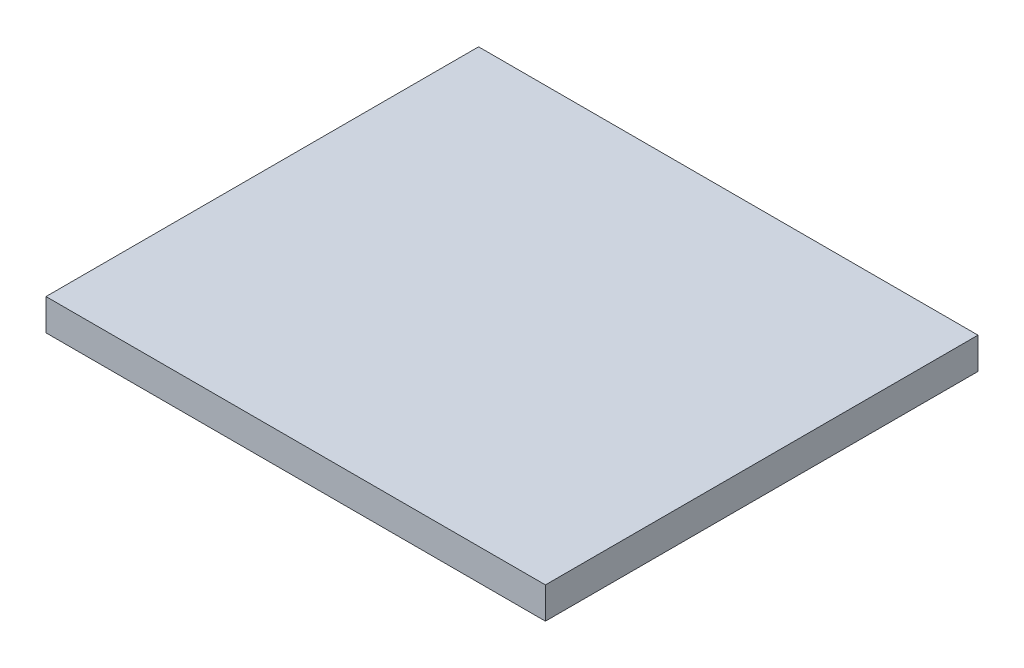
from build123d import *

# Parameters (mm, degrees)
CROQUIS1_W              = 101.6
CROQUIS1_H              = 6.4
SALIENTE_EXTRUIR2_DEPTH = 88


with BuildPart() as part:
    # Croquis1 → Saliente-Extruir2 (new body)
    with BuildSketch(Plane.XY):
        with Locations((50.8, 3.2)):
            Rectangle(CROQUIS1_W, CROQUIS1_H)
    extrude(amount=SALIENTE_EXTRUIR2_DEPTH)


solid = part.part
